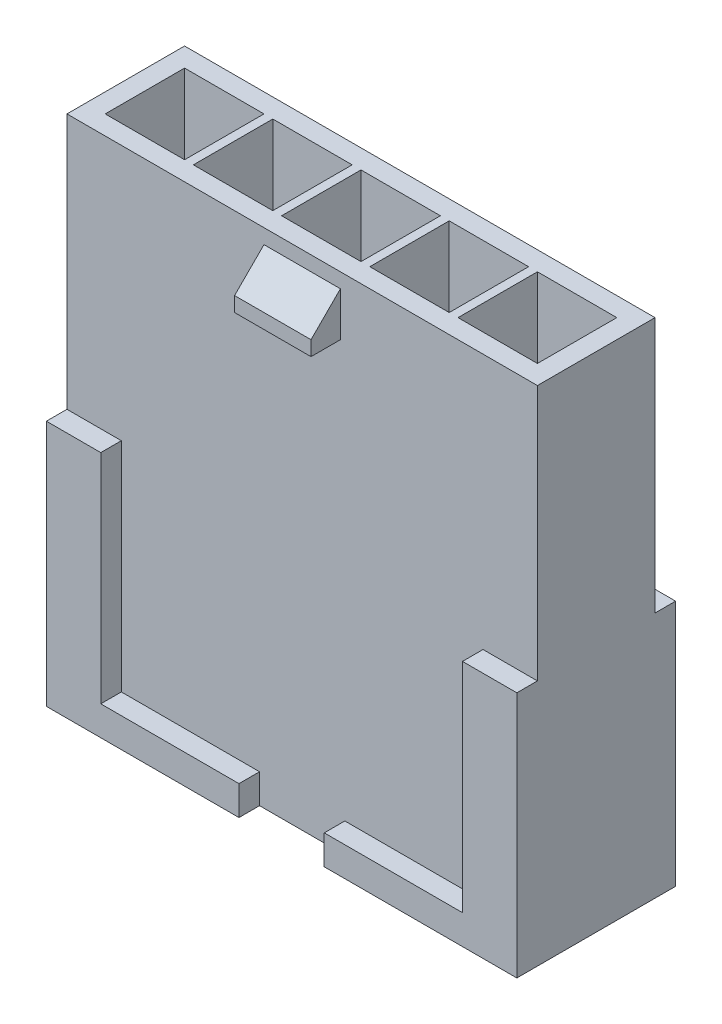
from build123d import *

# Parameters (mm, degrees)
SKETCH1_W           = 16
SKETCH1_H           = 4
SKETCH1_W_2         = 2.7
SKETCH1_H_2         = 2.7
BOSS_EXTRUDE1_DEPTH = 17.1
SKETCH2_W           = 4.7
SKETCH2_H           = 1
BOSS_EXTRUDE2_DEPTH = 0.7
BOSS_EXTRUDE3_DEPTH = 1.3
SKETCH4_W           = 2.9
SKETCH4_H           = 1
BOSS_EXTRUDE4_DEPTH = 0.7


with BuildPart() as part:
    # Sketch1 → Boss-Extrude1 (new body)
    with BuildSketch(Plane(origin=(0, 0, 0), x_dir=(1, 0, 0), z_dir=(0, 1, 0))):
        Rectangle(SKETCH1_W, SKETCH1_H)
        with Locations((3, 0)):
            Rectangle(SKETCH1_W_2, SKETCH1_H_2, mode=Mode.SUBTRACT)
        Rectangle(SKETCH1_W_2, SKETCH1_H_2, mode=Mode.SUBTRACT)
        with Locations((6, 0)):
            Rectangle(SKETCH1_W_2, SKETCH1_H_2, mode=Mode.SUBTRACT)
        with Locations((-6, 0)):
            Rectangle(SKETCH1_W_2, SKETCH1_H_2, mode=Mode.SUBTRACT)
        with Locations((-3, 0)):
            Rectangle(SKETCH1_W_2, SKETCH1_H_2, mode=Mode.SUBTRACT)
    extrude(amount=BOSS_EXTRUDE1_DEPTH)

    # Sketch2 → Boss-Extrude2 (add)
    with BuildSketch(Plane.XY.offset(2)):
        Polygon((-6.15, 8.4), (-8, 8.4), (-8, 0), (-6.15, 0), (-6.15, 1), align=None)
        with Locations((-3.8, 0.5)):
            Rectangle(SKETCH2_W, SKETCH2_H)
        with Locations((3.8, 0.5)):
            Rectangle(SKETCH2_W, SKETCH2_H)
        Polygon((6.15, 1), (6.15, 0), (8, 0), (8, 8.4), (6.15, 8.4), align=None)
    extrude(amount=BOSS_EXTRUDE2_DEPTH)

    # Sketch3 → Boss-Extrude3 (add, symmetric)
    with BuildSketch(Plane(origin=(0, 0, 0), x_dir=(0, 0, -1), z_dir=(1, 0, 0))):
        Polygon((-2, 16.6), (-3, 15.6), (-3, 15.1), (-2, 15.1), align=None)
    extrude(amount=BOSS_EXTRUDE3_DEPTH, both=True)

    # Sketch4 → Boss-Extrude4 (add)
    with BuildSketch(Plane(origin=(0, 0, -2), x_dir=(-1, 0, 0), z_dir=(0, 0, -1))):
        Polygon((-1.45, 0), (-1.45, 1), (-6.15, 1), (-6.15, 8.4), (-8, 8.4), (-8, 0), align=None)
        with Locations((0, 0.5)):
            Rectangle(SKETCH4_W, SKETCH4_H)
        Polygon((6.15, 8.4), (6.15, 1), (1.45, 1), (1.45, 0), (8, 0), (8, 8.4), align=None)
    extrude(amount=BOSS_EXTRUDE4_DEPTH)


solid = part.part
